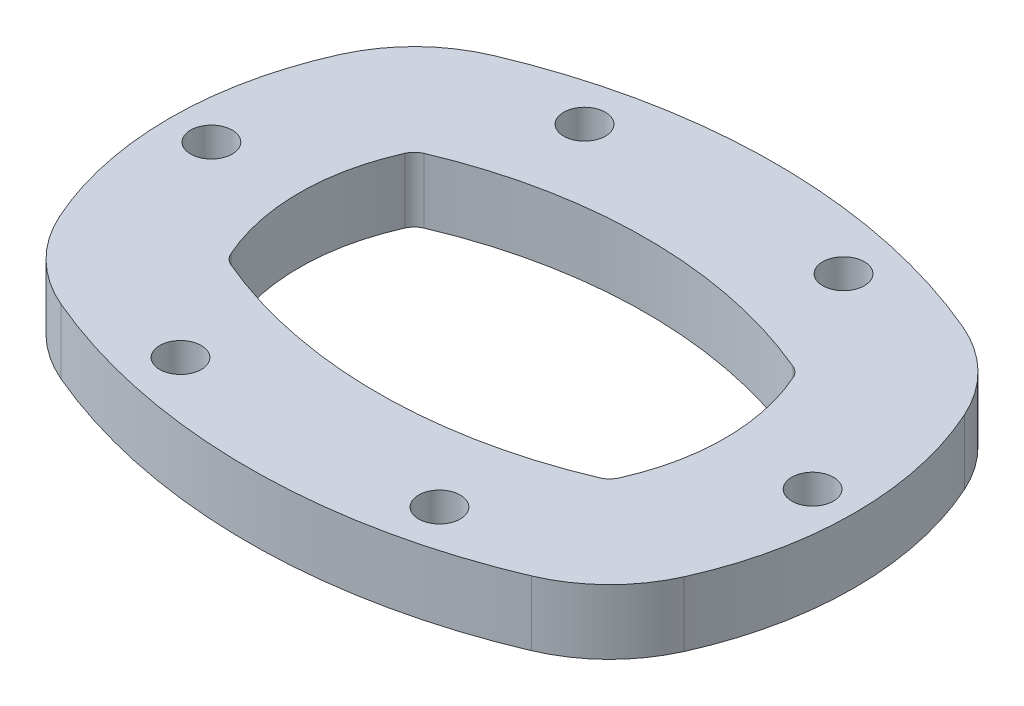
from build123d import *

# Parameters (mm, degrees)
SKETCH1_R           = 7.14375
BOSS_EXTRUDE1_DEPTH = 22.225


with BuildPart() as part:
    # Sketch1 → Boss-Extrude1 (new body)
    with BuildSketch(Plane(origin=(0, 0, 0), x_dir=(1, 0, 0), z_dir=(0, 1, 0))):
        with BuildLine():
            ThreePointArc((80.690921224, 74.058849944), (0, 90.4875), (-80.690921224, 74.058849944))
            ThreePointArc((-80.690921224, 74.058849944), (-96.385165084, 63.584590133), (-107.174095369, 48.104977984))
            ThreePointArc((-107.174095369, 48.104977984), (-117.475, 0), (-107.174095369, -48.104977984))
            ThreePointArc((-107.174095369, -48.104977984), (-96.385165084, -63.584590133), (-80.690921224, -74.058849944))
            ThreePointArc((-80.690921224, -74.058849944), (0, -90.4875), (80.690921224, -74.058849944))
            ThreePointArc((80.690921224, -74.058849944), (96.385165084, -63.584590133), (107.174095369, -48.104977984))
            ThreePointArc((107.174095369, -48.104977984), (117.475, 0), (107.174095369, 48.104977984))
            ThreePointArc((107.174095369, 48.104977984), (96.385165084, 63.584590133), (80.690921224, 74.058849944))
        make_face()
        with Locations((-103.1875, 0)):
            Circle(SKETCH1_R, mode=Mode.SUBTRACT)
        with Locations((-44.45, 69.354092252)):
            Circle(SKETCH1_R, mode=Mode.SUBTRACT)
        with Locations((103.1875, 0)):
            Circle(SKETCH1_R, mode=Mode.SUBTRACT)
        with Locations((44.45, 69.354092252)):
            Circle(SKETCH1_R, mode=Mode.SUBTRACT)
        with Locations((-44.45, -69.354092252)):
            Circle(SKETCH1_R, mode=Mode.SUBTRACT)
        with Locations((44.45, -69.354092252)):
            Circle(SKETCH1_R, mode=Mode.SUBTRACT)
        with BuildLine():
            ThreePointArc((-66.621734959, -29.903094423), (-73.025, 0), (-66.621734959, 29.903094423))
            ThreePointArc((-66.621734959, 29.903094423), (-65.273118673, 31.838045941), (-63.311338191, 33.147328418))
            ThreePointArc((-63.311338191, 33.147328418), (0, 46.0375), (63.311338191, 33.147328418))
            ThreePointArc((63.311338191, 33.147328418), (65.273118673, 31.838045941), (66.621734959, 29.903094423))
            ThreePointArc((66.621734959, 29.903094423), (73.025, 0), (66.621734959, -29.903094423))
            ThreePointArc((66.621734959, -29.903094423), (65.273118673, -31.838045941), (63.311338191, -33.147328418))
            ThreePointArc((63.311338191, -33.147328418), (0, -46.0375), (-63.311338191, -33.147328418))
            ThreePointArc((-63.311338191, -33.147328418), (-65.273118673, -31.838045941), (-66.621734959, -29.903094423))
        make_face(mode=Mode.SUBTRACT)
    extrude(amount=BOSS_EXTRUDE1_DEPTH)


solid = part.part
